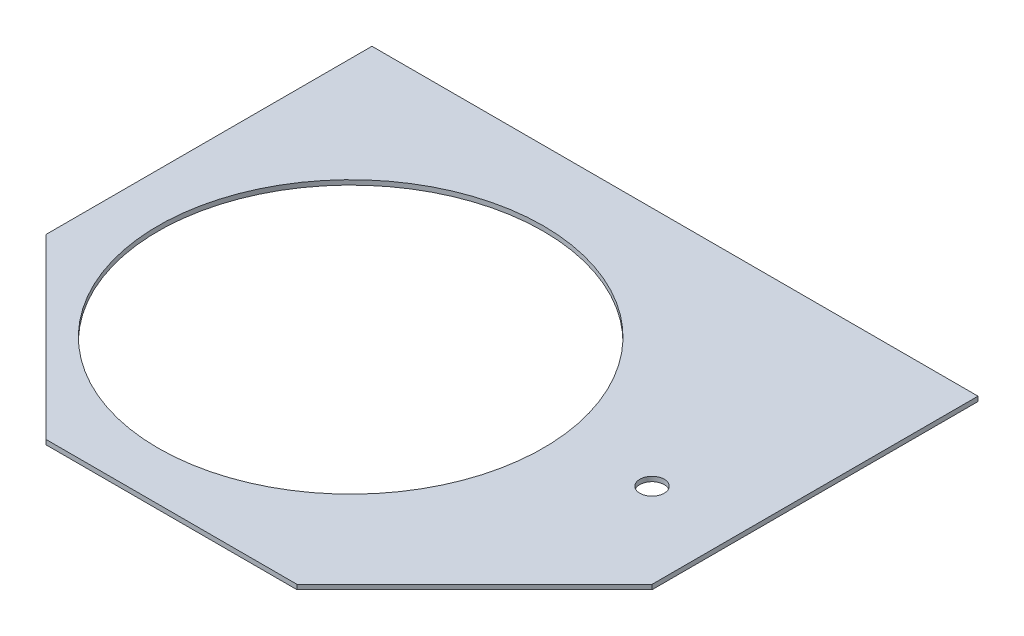
from build123d import *

# Parameters (mm, degrees)
BOSS_EXTRUDE1_DEPTH = 3.175
SKETCH3_R           = 130.556
CUT_EXTRUDE2_DEPTH  = 4.175
SKETCH4_R           = 8.255
CUT_EXTRUDE3_DEPTH  = 4.175


with BuildPart() as part:
    # Sketch1 → Boss-Extrude1 (new body)
    with BuildSketch(Plane(origin=(0, 0, 0), x_dir=(1, 0, 0), z_dir=(0, 1, 0))):
        Polygon((-205.417689271, 85.086792847), (-205.417689271, -85.086792847), (-85.086792847, -205.417689271), (85.086792847, -205.417689271), (205.417689271, -85.086792847), (205.417689271, 85.086792847), (205.417689271, 135.886792847), (-205.417689271, 135.886792847), align=None)
    extrude(amount=BOSS_EXTRUDE1_DEPTH)

    # Sketch3 → Cut-Extrude2 (cut, through all)
    with BuildSketch(Plane(origin=(0, 3.175, 0), x_dir=(-1, 0, 0), z_dir=(0, 1, 0))):
        with Locations(Location((41.979295667, 41.979295667, 0), (0, 0, 90))):  # turned: the seam where the file's is
            Circle(SKETCH3_R)
    extrude(amount=-CUT_EXTRUDE2_DEPTH, mode=Mode.SUBTRACT)

    # Sketch4 → Cut-Extrude3 (cut, through all)
    with BuildSketch(Plane(origin=(0, 3.175, 0), x_dir=(1, 0, 0), z_dir=(0, 1, 0))):
        with Locations(Location((147.81822682, -27.487330396, 0), (0, 0, 270))):  # turned: the seam where the file's is
            Circle(SKETCH4_R)
    extrude(amount=-CUT_EXTRUDE3_DEPTH, mode=Mode.SUBTRACT)


solid = part.part
